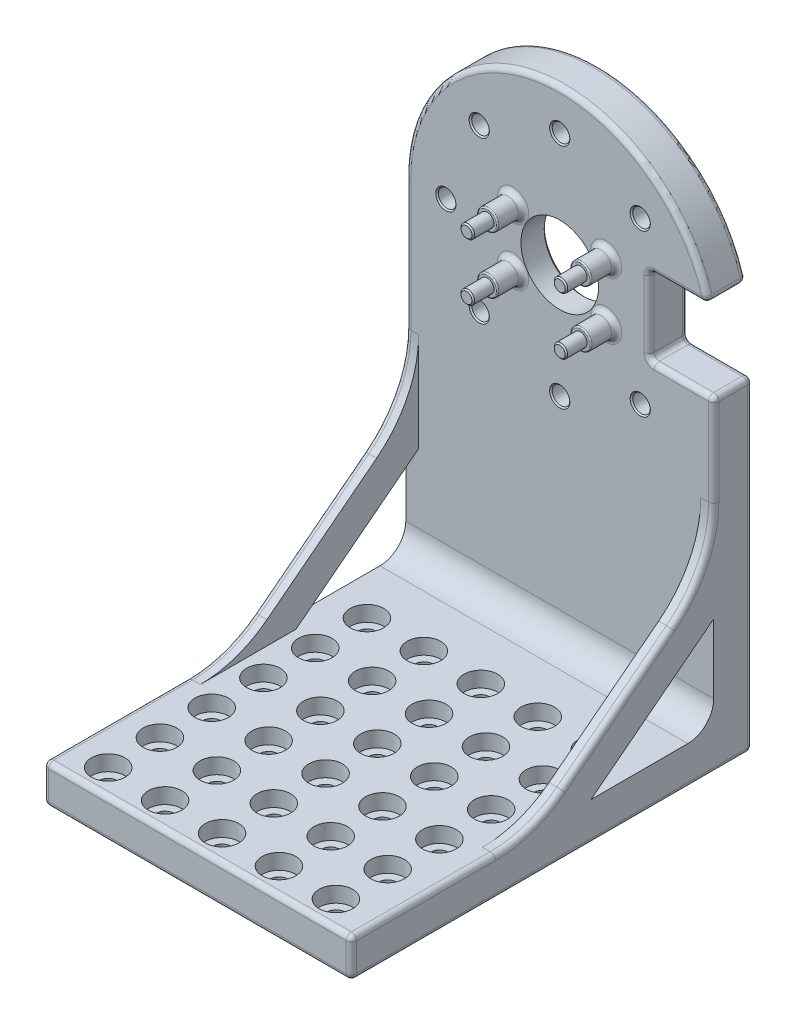
from build123d import *

# Parameters (mm, degrees)
SKETCH1_W                     = 59.5
SKETCH1_H                     = 100
BOSS_EXTRUDE3_DEPTH           = 7.5
SKETCH7_R                     = 7.5
CUT_EXTRUDE2_DEPTH            = 7.5
CIRPATTERN1_COUNT             = 8
SKETCH10_W                    = 12.5
SKETCH10_H                    = 15
CUT_EXTRUDE3_DEPTH            = 7.5
CUT_EXTRUDE4_DEPTH            = 7.5
FILLET2_R                     = 1
SKETCH12_R                    = 1.3
BOSS_EXTRUDE4_DEPTH           = 9
SKETCH13_R                    = 2
SKETCH13_R_2                  = 1.3
BOSS_EXTRUDE5_DEPTH           = 5
SKETCH14_W                    = 59.5
SKETCH14_H                    = 7.5
BOSS_EXTRUDE6_DEPTH           = 70
BOSS_EXTRUDE7_DEPTH           = 2.5
FILLET3_R                     = 21
FILLET4_R                     = 5
CBORE_FOR_M3_SHCS1_AT_2_COUNT = 2
CBORE_FOR_M3_SHCS1_AT_2_PITCH = 11
CBORE_FOR_M3_SHCS1_AT_3_COUNT = 2
CBORE_FOR_M3_SHCS1_AT_3_PITCH = 22
CBORE_FOR_M3_SHCS1_AT_4_COUNT = 2
CBORE_FOR_M3_SHCS1_AT_4_PITCH = 33
CBORE_FOR_M3_SHCS1_AT_5_COUNT = 2
CBORE_FOR_M3_SHCS1_AT_5_PITCH = 44
LPATTERN1_COUNT               = 6
LPATTERN1_PITCH               = 10
FILLET5_R                     = 1
FILLET6_R                     = 1
FILLET7_R                     = 0.25
CHAMFER2_SIZE                 = 0.25
CHAMFER3_SIZE                 = 0.25
SKETCH19_R                    = 15
SKETCH19_R_2                  = 7.5
CUT_EXTRUDE5_DEPTH            = 2.5
CHAMFER4_SIZE                 = 0.5


with BuildPart() as part:
    # Sketch1 → Boss-Extrude3 (new body)
    with BuildSketch(Plane.XY):
        Rectangle(SKETCH1_W, SKETCH1_H)
    extrude(amount=BOSS_EXTRUDE3_DEPTH)

    # Sketch7 → Cut-Extrude2 (cut)
    with BuildSketch(Plane.XY.offset(7.5)):
        with Locations((0, 20.25)):
            Circle(SKETCH7_R)
    extrude(amount=-CUT_EXTRUDE2_DEPTH, mode=Mode.SUBTRACT)

    # Sketch9 → M3 Clearance Hole2 (revolve, cut)
    with BuildSketch(Plane(origin=(0, 42.25, 7.5), x_dir=(0, -1, 0), z_dir=(1, 0, 0))):
        Polygon((0, 0), (0, 8.521463052), (1.7, 7.5), (1.7, 0), align=None)
    m3_clearance_hole2 = revolve(axis=Axis((0, 42.25, 13.85), (0, 0, -1)), mode=Mode.SUBTRACT)

    # CirPattern1: M3 Clearance Hole2 ×8 about axis, 1 skipped
    cirpattern1_axis = Axis((0, 20.25, 0), (0, 0, 1))
    add([m3_clearance_hole2.rotate(cirpattern1_axis, i * 360 / CIRPATTERN1_COUNT) for i in range(1, CIRPATTERN1_COUNT) if i not in (6,)], mode=Mode.SUBTRACT)

    # Sketch10 → Cut-Extrude3 (cut)
    with BuildSketch(Plane.XY.offset(7.5)):
        with Locations((23.5, 20.25)):
            Rectangle(SKETCH10_W, SKETCH10_H)
    extrude(amount=-CUT_EXTRUDE3_DEPTH, mode=Mode.SUBTRACT)

    # Sketch11 → Cut-Extrude4 (cut)
    with BuildSketch(Plane.XY.offset(7.5)):
        with BuildLine():
            Line((-29.75, 20.25), (-29.75, 50))
            Line((-29.75, 50), (0, 50))
            ThreePointArc((0, 50), (-21.03642674, 41.28642674), (-29.75, 20.25))
        make_face()
    cut_extrude4 = extrude(amount=-CUT_EXTRUDE4_DEPTH, mode=Mode.SUBTRACT)

    # Mirror1: Cut-Extrude4 across plane
    add(cut_extrude4.mirror(Plane(origin=(0, 0, 0), x_dir=(0, 0, 1), z_dir=(1, 0, 0))), mode=Mode.SUBTRACT)

    # Fillet2
    fillet2_edges = [part.edges().sort_by_distance(p)[0] for p in [
        (17.25, 27.75, 3.75),
        (17.25, 12.75, 3.75),
        (29.75, 12.75, 3.75),
        (28.789103842, 27.75, 3.75),
    ]]
    fillet(fillet2_edges, radius=FILLET2_R)

    # Sketch12 → Boss-Extrude4 (add)
    with BuildSketch(Plane.XY.offset(7.5)):
        with Locations((-9, 25.75)):
            Circle(SKETCH12_R)
        with Locations((9, 25.75)):
            Circle(SKETCH12_R)
        with Locations((9, 14.75)):
            Circle(SKETCH12_R)
        with Locations((-9, 14.75)):
            Circle(SKETCH12_R)
    extrude(amount=BOSS_EXTRUDE4_DEPTH)

    # Sketch13 → Boss-Extrude5 (add)
    with BuildSketch(Plane.XY.offset(7.5)):
        with Locations((-9, 25.75)):
            Circle(SKETCH13_R)
        with Locations((-9, 25.75)):
            Circle(SKETCH13_R_2, mode=Mode.SUBTRACT)
        with Locations((9, 25.75)):
            Circle(SKETCH13_R)
        with Locations((9, 25.75)):
            Circle(SKETCH13_R_2, mode=Mode.SUBTRACT)
        with Locations((9, 14.75)):
            Circle(SKETCH13_R)
        with Locations((9, 14.75)):
            Circle(SKETCH13_R_2, mode=Mode.SUBTRACT)
        with Locations((-9, 14.75)):
            Circle(SKETCH13_R)
        with Locations((-9, 14.75)):
            Circle(SKETCH13_R_2, mode=Mode.SUBTRACT)
    extrude(amount=BOSS_EXTRUDE5_DEPTH)

    # Sketch14 → Boss-Extrude6 (add)
    with BuildSketch(Plane.XY.offset(7.5)):
        with Locations((0, -46.25)):
            Rectangle(SKETCH14_W, SKETCH14_H)
    extrude(amount=BOSS_EXTRUDE6_DEPTH)

    # Sketch15 → Boss-Extrude7 (add)
    with BuildSketch(Plane(origin=(29.75, 0, 0), x_dir=(0, 0, -1), z_dir=(1, 0, 0))):
        Polygon((-7.5, -24.122850037), (-7.5, -15.375), (-42.5, -42.5), (-31.212451565, -42.5), align=None)
    boss_extrude7 = extrude(amount=-BOSS_EXTRUDE7_DEPTH)

    # Mirror2: Boss-Extrude7 across plane
    add(boss_extrude7.mirror(Plane(origin=(0, 0, 0), x_dir=(0, 0, 1), z_dir=(1, 0, 0))))

    # Fillet3
    fillet3_edges = [part.edges().sort_by_distance(p)[0] for p in [
        (28.5, -42.5, 42.5),
        (28.5, -15.375, 7.5),
        (-28.5, -15.375, 7.5),
        (-28.5, -42.5, 42.5),
    ]]
    fillet(fillet3_edges, radius=FILLET3_R)

    # Fillet4
    fillet4_edges = [part.edges().sort_by_distance(p)[0] for p in [
        (0, -42.5, 7.5),
    ]]
    fillet(fillet4_edges, radius=FILLET4_R)

    # Sketch18 → CBORE for M3 SHCS1 (revolve, cut)
    with BuildSketch(Plane(origin=(-22.25, -42.5, 22.5), x_dir=(0, 0, 1), z_dir=(1, 0, 0))):
        Polygon((0, 0), (0, 8.521463052), (1.7, 7.5), (1.7, 3), (3.25, 3), (3.25, 0), align=None)
    cbore_for_m3_shcs1 = revolve(axis=Axis((-22.25, -36.15, 22.5), (0, -1, 0)), mode=Mode.SUBTRACT)

    # CBORE for M3 SHCS1 at 2: CBORE for M3 SHCS1 ×2
    with Locations(*[(i * CBORE_FOR_M3_SHCS1_AT_2_PITCH, 0, 0) for i in range(1, CBORE_FOR_M3_SHCS1_AT_2_COUNT)]):
        add(cbore_for_m3_shcs1, mode=Mode.SUBTRACT)

    # CBORE for M3 SHCS1 at 3: CBORE for M3 SHCS1 ×2
    with Locations(*[(i * CBORE_FOR_M3_SHCS1_AT_3_PITCH, 0, 0) for i in range(1, CBORE_FOR_M3_SHCS1_AT_3_COUNT)]):
        add(cbore_for_m3_shcs1, mode=Mode.SUBTRACT)

    # CBORE for M3 SHCS1 at 4: CBORE for M3 SHCS1 ×2
    with Locations(*[(i * CBORE_FOR_M3_SHCS1_AT_4_PITCH, 0, 0) for i in range(1, CBORE_FOR_M3_SHCS1_AT_4_COUNT)]):
        add(cbore_for_m3_shcs1, mode=Mode.SUBTRACT)

    # CBORE for M3 SHCS1 at 5: CBORE for M3 SHCS1 ×2
    with Locations(*[(i * CBORE_FOR_M3_SHCS1_AT_5_PITCH, 0, 0) for i in range(1, CBORE_FOR_M3_SHCS1_AT_5_COUNT)]):
        add(cbore_for_m3_shcs1, mode=Mode.SUBTRACT)

    # LPattern1: CBORE for M3 SHCS1 ×6
    with Locations(*[(0, 0, i * LPATTERN1_PITCH) for i in range(1, LPATTERN1_COUNT)]):
        add(cbore_for_m3_shcs1, mode=Mode.SUBTRACT)

    # LPattern1 copy 1 sketch → LPattern1 copy 1 (revolve, cut)
    with BuildSketch(Plane(origin=(-11.25, -42.5, 32.5), x_dir=(0, 0, 1), z_dir=(1, 0, 0))):
        Polygon((0, 0), (0, 8.521463052), (1.7, 7.5), (1.7, 3), (3.25, 3), (3.25, 0), align=None)
    revolve(axis=Axis((-11.25, -36.15, 32.5), (0, -1, 0)), mode=Mode.SUBTRACT)

    # LPattern1 copy 2 sketch → LPattern1 copy 2 (revolve, cut)
    with BuildSketch(Plane(origin=(-11.25, -42.5, 42.5), x_dir=(0, 0, 1), z_dir=(1, 0, 0))):
        Polygon((0, 0), (0, 8.521463052), (1.7, 7.5), (1.7, 3), (3.25, 3), (3.25, 0), align=None)
    revolve(axis=Axis((-11.25, -36.15, 42.5), (0, -1, 0)), mode=Mode.SUBTRACT)

    # LPattern1 copy 3 sketch → LPattern1 copy 3 (revolve, cut)
    with BuildSketch(Plane(origin=(-11.25, -42.5, 52.5), x_dir=(0, 0, 1), z_dir=(1, 0, 0))):
        Polygon((0, 0), (0, 8.521463052), (1.7, 7.5), (1.7, 3), (3.25, 3), (3.25, 0), align=None)
    revolve(axis=Axis((-11.25, -36.15, 52.5), (0, -1, 0)), mode=Mode.SUBTRACT)

    # LPattern1 copy 4 sketch → LPattern1 copy 4 (revolve, cut)
    with BuildSketch(Plane(origin=(-11.25, -42.5, 62.5), x_dir=(0, 0, 1), z_dir=(1, 0, 0))):
        Polygon((0, 0), (0, 8.521463052), (1.7, 7.5), (1.7, 3), (3.25, 3), (3.25, 0), align=None)
    revolve(axis=Axis((-11.25, -36.15, 62.5), (0, -1, 0)), mode=Mode.SUBTRACT)

    # LPattern1 copy 5 sketch → LPattern1 copy 5 (revolve, cut)
    with BuildSketch(Plane(origin=(-11.25, -42.5, 72.5), x_dir=(0, 0, 1), z_dir=(1, 0, 0))):
        Polygon((0, 0), (0, 8.521463052), (1.7, 7.5), (1.7, 3), (3.25, 3), (3.25, 0), align=None)
    revolve(axis=Axis((-11.25, -36.15, 72.5), (0, -1, 0)), mode=Mode.SUBTRACT)

    # LPattern1 copy 6 sketch → LPattern1 copy 6 (revolve, cut)
    with BuildSketch(Plane(origin=(-0.25, -42.5, 32.5), x_dir=(0, 0, 1), z_dir=(1, 0, 0))):
        Polygon((0, 0), (0, 8.521463052), (1.7, 7.5), (1.7, 3), (3.25, 3), (3.25, 0), align=None)
    revolve(axis=Axis((-0.25, -36.15, 32.5), (0, -1, 0)), mode=Mode.SUBTRACT)

    # LPattern1 copy 7 sketch → LPattern1 copy 7 (revolve, cut)
    with BuildSketch(Plane(origin=(-0.25, -42.5, 42.5), x_dir=(0, 0, 1), z_dir=(1, 0, 0))):
        Polygon((0, 0), (0, 8.521463052), (1.7, 7.5), (1.7, 3), (3.25, 3), (3.25, 0), align=None)
    revolve(axis=Axis((-0.25, -36.15, 42.5), (0, -1, 0)), mode=Mode.SUBTRACT)

    # LPattern1 copy 8 sketch → LPattern1 copy 8 (revolve, cut)
    with BuildSketch(Plane(origin=(-0.25, -42.5, 52.5), x_dir=(0, 0, 1), z_dir=(1, 0, 0))):
        Polygon((0, 0), (0, 8.521463052), (1.7, 7.5), (1.7, 3), (3.25, 3), (3.25, 0), align=None)
    revolve(axis=Axis((-0.25, -36.15, 52.5), (0, -1, 0)), mode=Mode.SUBTRACT)

    # LPattern1 copy 9 sketch → LPattern1 copy 9 (revolve, cut)
    with BuildSketch(Plane(origin=(-0.25, -42.5, 62.5), x_dir=(0, 0, 1), z_dir=(1, 0, 0))):
        Polygon((0, 0), (0, 8.521463052), (1.7, 7.5), (1.7, 3), (3.25, 3), (3.25, 0), align=None)
    revolve(axis=Axis((-0.25, -36.15, 62.5), (0, -1, 0)), mode=Mode.SUBTRACT)

    # LPattern1 copy 10 sketch → LPattern1 copy 10 (revolve, cut)
    with BuildSketch(Plane(origin=(-0.25, -42.5, 72.5), x_dir=(0, 0, 1), z_dir=(1, 0, 0))):
        Polygon((0, 0), (0, 8.521463052), (1.7, 7.5), (1.7, 3), (3.25, 3), (3.25, 0), align=None)
    revolve(axis=Axis((-0.25, -36.15, 72.5), (0, -1, 0)), mode=Mode.SUBTRACT)

    # LPattern1 copy 11 sketch → LPattern1 copy 11 (revolve, cut)
    with BuildSketch(Plane(origin=(10.75, -42.5, 32.5), x_dir=(0, 0, 1), z_dir=(1, 0, 0))):
        Polygon((0, 0), (0, 8.521463052), (1.7, 7.5), (1.7, 3), (3.25, 3), (3.25, 0), align=None)
    revolve(axis=Axis((10.75, -36.15, 32.5), (0, -1, 0)), mode=Mode.SUBTRACT)

    # LPattern1 copy 12 sketch → LPattern1 copy 12 (revolve, cut)
    with BuildSketch(Plane(origin=(10.75, -42.5, 42.5), x_dir=(0, 0, 1), z_dir=(1, 0, 0))):
        Polygon((0, 0), (0, 8.521463052), (1.7, 7.5), (1.7, 3), (3.25, 3), (3.25, 0), align=None)
    revolve(axis=Axis((10.75, -36.15, 42.5), (0, -1, 0)), mode=Mode.SUBTRACT)

    # LPattern1 copy 13 sketch → LPattern1 copy 13 (revolve, cut)
    with BuildSketch(Plane(origin=(10.75, -42.5, 52.5), x_dir=(0, 0, 1), z_dir=(1, 0, 0))):
        Polygon((0, 0), (0, 8.521463052), (1.7, 7.5), (1.7, 3), (3.25, 3), (3.25, 0), align=None)
    revolve(axis=Axis((10.75, -36.15, 52.5), (0, -1, 0)), mode=Mode.SUBTRACT)

    # LPattern1 copy 14 sketch → LPattern1 copy 14 (revolve, cut)
    with BuildSketch(Plane(origin=(10.75, -42.5, 62.5), x_dir=(0, 0, 1), z_dir=(1, 0, 0))):
        Polygon((0, 0), (0, 8.521463052), (1.7, 7.5), (1.7, 3), (3.25, 3), (3.25, 0), align=None)
    revolve(axis=Axis((10.75, -36.15, 62.5), (0, -1, 0)), mode=Mode.SUBTRACT)

    # LPattern1 copy 15 sketch → LPattern1 copy 15 (revolve, cut)
    with BuildSketch(Plane(origin=(10.75, -42.5, 72.5), x_dir=(0, 0, 1), z_dir=(1, 0, 0))):
        Polygon((0, 0), (0, 8.521463052), (1.7, 7.5), (1.7, 3), (3.25, 3), (3.25, 0), align=None)
    revolve(axis=Axis((10.75, -36.15, 72.5), (0, -1, 0)), mode=Mode.SUBTRACT)

    # LPattern1 copy 16 sketch → LPattern1 copy 16 (revolve, cut)
    with BuildSketch(Plane(origin=(21.75, -42.5, 32.5), x_dir=(0, 0, 1), z_dir=(1, 0, 0))):
        Polygon((0, 0), (0, 8.521463052), (1.7, 7.5), (1.7, 3), (3.25, 3), (3.25, 0), align=None)
    revolve(axis=Axis((21.75, -36.15, 32.5), (0, -1, 0)), mode=Mode.SUBTRACT)

    # LPattern1 copy 17 sketch → LPattern1 copy 17 (revolve, cut)
    with BuildSketch(Plane(origin=(21.75, -42.5, 42.5), x_dir=(0, 0, 1), z_dir=(1, 0, 0))):
        Polygon((0, 0), (0, 8.521463052), (1.7, 7.5), (1.7, 3), (3.25, 3), (3.25, 0), align=None)
    revolve(axis=Axis((21.75, -36.15, 42.5), (0, -1, 0)), mode=Mode.SUBTRACT)

    # LPattern1 copy 18 sketch → LPattern1 copy 18 (revolve, cut)
    with BuildSketch(Plane(origin=(21.75, -42.5, 52.5), x_dir=(0, 0, 1), z_dir=(1, 0, 0))):
        Polygon((0, 0), (0, 8.521463052), (1.7, 7.5), (1.7, 3), (3.25, 3), (3.25, 0), align=None)
    revolve(axis=Axis((21.75, -36.15, 52.5), (0, -1, 0)), mode=Mode.SUBTRACT)

    # LPattern1 copy 19 sketch → LPattern1 copy 19 (revolve, cut)
    with BuildSketch(Plane(origin=(21.75, -42.5, 62.5), x_dir=(0, 0, 1), z_dir=(1, 0, 0))):
        Polygon((0, 0), (0, 8.521463052), (1.7, 7.5), (1.7, 3), (3.25, 3), (3.25, 0), align=None)
    revolve(axis=Axis((21.75, -36.15, 62.5), (0, -1, 0)), mode=Mode.SUBTRACT)

    # LPattern1 copy 20 sketch → LPattern1 copy 20 (revolve, cut)
    with BuildSketch(Plane(origin=(21.75, -42.5, 72.5), x_dir=(0, 0, 1), z_dir=(1, 0, 0))):
        Polygon((0, 0), (0, 8.521463052), (1.7, 7.5), (1.7, 3), (3.25, 3), (3.25, 0), align=None)
    revolve(axis=Axis((21.75, -36.15, 72.5), (0, -1, 0)), mode=Mode.SUBTRACT)

    # Fillet5
    fillet5_edges = [part.edges().sort_by_distance(p)[0] for p in [
        (22.857375068, 27.75, 7.5),
        (23.5, 12.75, 7.5),
        (17.25, 20.25, 7.5),
        (28.269626577, 28.156557574, 7.5),
        (29.457106781, 12.457106781, 7.5),
        (23.5, 12.75, 0),
        (22.857375068, 27.75, 0),
        (17.25, 20.25, 0),
        (28.269626577, 28.156557574, 0),
        (29.457106781, 12.457106781, 0),
        (17.542893219, 13.042893219, 7.5),
        (17.542893219, 13.042893219, 0),
        (17.542893219, 27.457106781, 7.5),
        (17.542893219, 27.457106781, 0),
        (-29.75, -42.5, 63.592464484),
        (29.75, -42.5, 63.592464484),
        (-29.75, -46.25, 77.5),
        (0, -50, 77.5),
        (29.75, -46.25, 77.5),
        (0, -42.5, 77.5),
        (-29.75, -29.88955612, 26.22845951),
        (29.75, -29.88955612, 26.22845951),
        (29.75, 3.334159975, 7.5),
        (-29.75, -41.369235491, 42.886879175),
        (29.75, -41.369235491, 42.886879175),
        (29.75, -14.324404094, 9.643381739),
        (-29.75, -14.324404094, 9.643381739),
        (21.75, -50, 20.8),
        (10.75, -50, 20.8),
        (-0.25, -50, 20.8),
        (-11.25, -50, 20.8),
        (-22.25, -50, 20.8),
        (-22.25, -50, 30.8),
        (-22.25, -50, 40.8),
        (-22.25, -50, 50.8),
        (-22.25, -50, 60.8),
        (-22.25, -50, 70.8),
        (21.75, -50, 30.8),
        (21.75, -50, 40.8),
        (21.75, -50, 50.8),
        (21.75, -50, 60.8),
        (21.75, -50, 70.8),
        (10.75, -50, 30.8),
        (10.75, -50, 40.8),
        (10.75, -50, 50.8),
        (10.75, -50, 60.8),
        (10.75, -50, 70.8),
        (-0.25, -50, 30.8),
        (-0.25, -50, 40.8),
        (-0.25, -50, 50.8),
        (-0.25, -50, 60.8),
        (-0.25, -50, 70.8),
        (-11.25, -50, 30.8),
        (-11.25, -50, 40.8),
        (-11.25, -50, 50.8),
        (-11.25, -50, 60.8),
        (-11.25, -50, 70.8),
        (0, -50, 0),
        (29.75, -19.125, 0),
        (-29.75, -14.875, 0),
        (-29.75, 7.584159975, 7.5),
        (29.75, -50, 38.75),
        (-4.447816188, 49.665632428, 7.5),
        (-29.75, -50, 38.75),
        (-4.447816188, 49.665632428, 0),
    ]]
    fillet(fillet5_edges, radius=FILLET5_R)

    # Fillet6
    fillet6_edges = [part.edges().sort_by_distance(p)[0] for p in [
        (-11, 25.75, 7.5),
        (7, 25.75, 7.5),
        (7, 14.75, 7.5),
        (-11, 14.75, 7.5),
    ]]
    fillet(fillet6_edges, radius=FILLET6_R)

    # Fillet7
    fillet7_edges = [part.edges().sort_by_distance(p)[0] for p in [
        (-11, 25.75, 12.5),
        (7, 25.75, 12.5),
        (7, 14.75, 12.5),
        (-11, 14.75, 12.5),
    ]]
    fillet(fillet7_edges, radius=FILLET7_R)

    # Chamfer2
    chamfer2_edges = [part.edges().sort_by_distance(p)[0] for p in [
        (-10.3, 25.75, 16.5),
        (7.7, 25.75, 16.5),
        (7.7, 14.75, 16.5),
        (-10.3, 14.75, 16.5),
    ]]
    chamfer(chamfer2_edges, length=CHAMFER2_SIZE)

    # Chamfer3
    chamfer3_edges = [part.edges().sort_by_distance(p)[0] for p in [
        (0, 43.95, 7.5),
        (-16.758430714, 37.008430714, 7.5),
        (-23.7, 20.25, 7.5),
        (-16.758430714, 3.491569286, 7.5),
        (-16.758430714, 3.491569286, 0),
        (0, -3.45, 7.5),
        (16.758430714, 3.491569286, 7.5),
        (16.758430714, 37.008430714, 7.5),
    ]]
    chamfer(chamfer3_edges, length=CHAMFER3_SIZE)

    # Sketch19 → Cut-Extrude5 (cut)
    with BuildSketch(Plane(origin=(0, 0, 0), x_dir=(-1, 0, 0), z_dir=(0, 0, -1))):
        with Locations((0, 20.25)):
            Circle(SKETCH19_R)
        with Locations((0, 20.25)):
            Circle(SKETCH19_R_2, mode=Mode.SUBTRACT)
    extrude(amount=-CUT_EXTRUDE5_DEPTH, mode=Mode.SUBTRACT)

    # Chamfer4
    chamfer4_edges = [part.edges().sort_by_distance(p)[0] for p in [
        (15, 20.25, 2.5),
        (-7.5, 20.25, 2.5),
        (15, 20.25, 0),
    ]]
    chamfer(chamfer4_edges, length=CHAMFER4_SIZE)


solid = part.part
